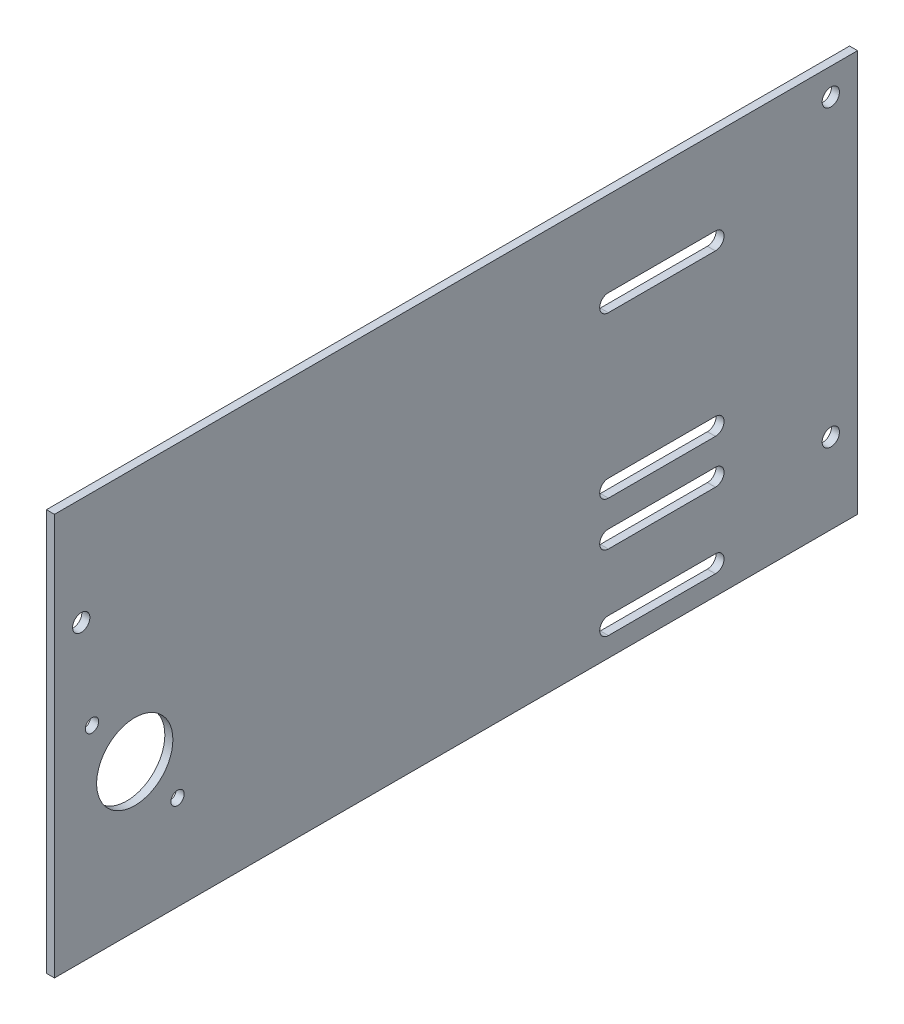
from build123d import *

# Parameters (mm, degrees)
SKETCH1_W           = 300
SKETCH1_H           = 150
SKETCH1_R           = 14.235
BOSS_EXTRUDE1_DEPTH = 3
CUT_EXTRUDE1_REACH  = 5
SKETCH2_R           = 3.225
SKETCH3_R           = 2.4892
CUT_EXTRUDE2_DEPTH  = 4


with BuildPart() as part:
    # Sketch1 → Boss-Extrude1 (new body)
    with BuildSketch(Plane(origin=(0, 0, 0), x_dir=(0, 0, -1), z_dir=(1, 0, 0))):
        with Locations((150, 75)):
            Rectangle(SKETCH1_W, SKETCH1_H)
        with Locations((30, 55)):
            Circle(SKETCH1_R, mode=Mode.SUBTRACT)
    extrude(amount=BOSS_EXTRUDE1_DEPTH)

    # Sketch2 → Cut-Extrude1 (cut, up to next)
    with BuildSketch(Plane.ZY, mode=Mode.PRIVATE) as cut_extrude1_sk1:
        with Locations((-290, 140)):
            Circle(SKETCH2_R)
    cut_extrude1_tool1 = extrude(cut_extrude1_sk1.sketch, amount=-CUT_EXTRUDE1_REACH, mode=Mode.PRIVATE) & part.part
    add(cut_extrude1_tool1.solids().sort_by_distance((0, 140, -290))[0], mode=Mode.SUBTRACT)
    # Sketch2 → Cut-Extrude1 (cut, up to next)
    with BuildSketch(Plane.ZY, mode=Mode.PRIVATE) as cut_extrude1_sk2:
        with Locations((-10, 110)):
            Circle(SKETCH2_R)
    cut_extrude1_tool2 = extrude(cut_extrude1_sk2.sketch, amount=-CUT_EXTRUDE1_REACH, mode=Mode.PRIVATE) & part.part
    add(cut_extrude1_tool2.solids().sort_by_distance((0, 110, -10))[0], mode=Mode.SUBTRACT)
    # Sketch2 → Cut-Extrude1 (cut, up to next)
    with BuildSketch(Plane.ZY, mode=Mode.PRIVATE) as cut_extrude1_sk3:
        with Locations((-290, 30)):
            Circle(SKETCH2_R)
    cut_extrude1_tool3 = extrude(cut_extrude1_sk3.sketch, amount=-CUT_EXTRUDE1_REACH, mode=Mode.PRIVATE) & part.part
    add(cut_extrude1_tool3.solids().sort_by_distance((0, 30, -290))[0], mode=Mode.SUBTRACT)
    # Sketch2 → Cut-Extrude1 (cut, up to next)
    with BuildSketch(Plane.ZY, mode=Mode.PRIVATE) as cut_extrude1_sk4:
        with BuildLine():
            Line((-246.901029004, 58.225), (-206.901029004, 58.225))
            ThreePointArc((-206.901029004, 58.225), (-203.676029004, 55), (-206.901029004, 51.775))
            Line((-206.901029004, 51.775), (-246.901029004, 51.775))
            ThreePointArc((-246.901029004, 51.775), (-250.126029004, 55), (-246.901029004, 58.225))
        make_face()
    cut_extrude1_tool4 = extrude(cut_extrude1_sk4.sketch, amount=-CUT_EXTRUDE1_REACH, mode=Mode.PRIVATE) & part.part
    add(cut_extrude1_tool4.solids().sort_by_distance((0, 55, -226.901029))[0], mode=Mode.SUBTRACT)
    # Sketch2 → Cut-Extrude1 (cut, up to next)
    with BuildSketch(Plane.ZY, mode=Mode.PRIVATE) as cut_extrude1_sk5:
        with BuildLine():
            Line((-206.901029004, 111.77), (-246.901029004, 111.77))
            ThreePointArc((-246.901029004, 111.77), (-250.131029004, 115), (-246.901029004, 118.23))
            Line((-246.901029004, 118.23), (-206.901029004, 118.23))
            ThreePointArc((-206.901029004, 118.23), (-203.671029004, 115), (-206.901029004, 111.77))
        make_face()
    cut_extrude1_tool5 = extrude(cut_extrude1_sk5.sketch, amount=-CUT_EXTRUDE1_REACH, mode=Mode.PRIVATE) & part.part
    add(cut_extrude1_tool5.solids().sort_by_distance((0, 115, -226.901029))[0], mode=Mode.SUBTRACT)
    # Sketch2 → Cut-Extrude1 (cut, up to next)
    with BuildSketch(Plane.ZY, mode=Mode.PRIVATE) as cut_extrude1_sk6:
        with BuildLine():
            Line((-246.901029004, 41.775), (-206.901029004, 41.775))
            ThreePointArc((-206.901029004, 41.775), (-203.676029004, 38.55), (-206.901029004, 35.325))
            Line((-206.901029004, 35.325), (-246.901029004, 35.325))
            ThreePointArc((-246.901029004, 35.325), (-250.126029004, 38.55), (-246.901029004, 41.775))
        make_face()
    cut_extrude1_tool6 = extrude(cut_extrude1_sk6.sketch, amount=-CUT_EXTRUDE1_REACH, mode=Mode.PRIVATE) & part.part
    add(cut_extrude1_tool6.solids().sort_by_distance((0, 38.55, -226.901029))[0], mode=Mode.SUBTRACT)
    # Sketch2 → Cut-Extrude1 (cut, up to next)
    with BuildSketch(Plane.ZY, mode=Mode.PRIVATE) as cut_extrude1_sk7:
        with BuildLine():
            Line((-246.901029004, 13.775), (-206.901029004, 13.775))
            ThreePointArc((-206.901029004, 13.775), (-203.676029004, 10.55), (-206.901029004, 7.325))
            Line((-206.901029004, 7.325), (-246.901029004, 7.325))
            ThreePointArc((-246.901029004, 7.325), (-250.126029004, 10.55), (-246.901029004, 13.775))
        make_face()
    cut_extrude1_tool7 = extrude(cut_extrude1_sk7.sketch, amount=-CUT_EXTRUDE1_REACH, mode=Mode.PRIVATE) & part.part
    add(cut_extrude1_tool7.solids().sort_by_distance((0, 10.55, -226.901029))[0], mode=Mode.SUBTRACT)

    # Sketch3 → Cut-Extrude2 (cut, through all)
    with BuildSketch(Plane(origin=(3, 0, 0), x_dir=(0, 0, -1), z_dir=(1, 0, 0))):
        with Locations((14.005743185, 74.73179538)):
            Circle(SKETCH3_R)
        with Locations((45.994256815, 35.26820462)):
            Circle(SKETCH3_R)
    extrude(amount=-CUT_EXTRUDE2_DEPTH, mode=Mode.SUBTRACT)


solid = part.part
